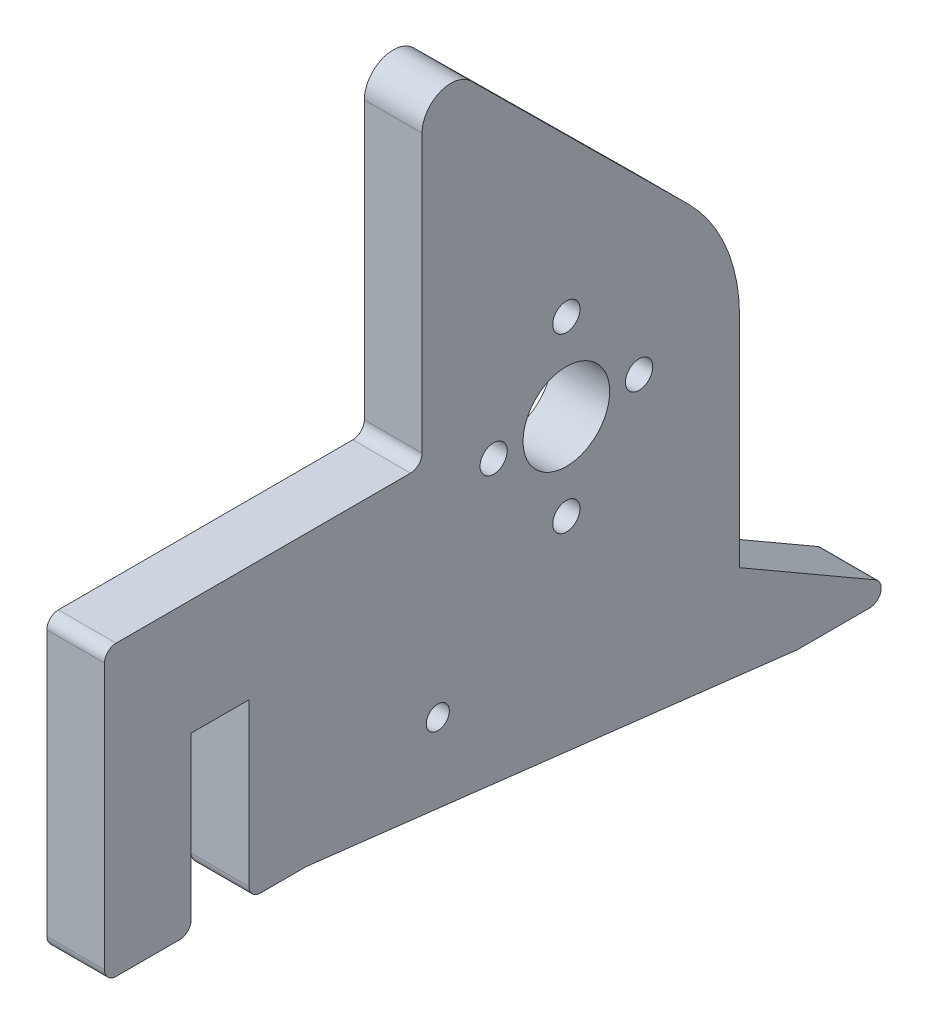
from build123d import *

# Parameters (mm, degrees)
BOSS_EXTRUDE1_DEPTH     = 3.175
CUT_EXTRUDE4_DEPTH      = 64.579325453
CUT_EXTRUDE4_DEPTH_BACK = 64.579325453
SKETCH15_W              = 6.35
SKETCH15_H              = 19.05
SKETCH37_R              = 1.5
SKETCH37_R_2            = 4.7625
CUT_EXTRUDE15_DEPTH     = 64.816710194
SKETCH47_R              = 1.27
CUT_EXTRUDE18_DEPTH     = 64.816710194
FILLET14_R              = 1.27
FILLET15_R              = 1.27


with BuildPart() as part:
    # Sketch5 → Boss-Extrude1 (new, symmetric)
    with BuildSketch(Plane(origin=(0, 0, 0), x_dir=(0, 0, -1), z_dir=(1, 0, 0))):
        with BuildLine():
            Line((19.05, -23.926477372), (19.05, 0))
            ThreePointArc((19.05, 0), (17.582566657, 7.331838088), (13.406341233, 13.534124085))
            Line((13.406341233, 13.534124085), (-10.465609794, 37.180687347))
            ThreePointArc((-10.465609794, 37.180687347), (-13.921973015, 37.855427776), (-15.875, 34.925))
            Line((-15.875, 34.925), (-15.875, 3.175))
            Line((-15.875, 3.175), (-50.8, 3.175))
            Line((-50.8, 3.175), (-50.8, -28.575))
            Line((-50.8, -28.575), (-28.575, -28.575))
            Line((-28.575, -28.575), (25.4, -34.925))
            Line((25.4, -34.925), (38.1, -34.925))
            Line((38.1, -34.925), (19.05, -23.926477372))
        make_face()
    extrude(amount=BOSS_EXTRUDE1_DEPTH, both=True)

    # Sketch15 → Cut-Extrude4 (cut, two sides: drawn at the far end of the back side and taken through both)
    with BuildSketch(Plane(origin=(0, 0, 0), x_dir=(0, 0, -1), z_dir=(1, 0, 0)).offset(-CUT_EXTRUDE4_DEPTH_BACK)):
        with Locations((-38.1, -19.05)):
            Rectangle(SKETCH15_W, SKETCH15_H)
    extrude(amount=CUT_EXTRUDE4_DEPTH + CUT_EXTRUDE4_DEPTH_BACK, mode=Mode.SUBTRACT)

    # Sketch37 → Cut-Extrude15 (cut, through all)
    with BuildSketch(Plane(origin=(3.175, 0, 0), x_dir=(0, 0, -1), z_dir=(1, 0, 0))):
        with Locations((0, -9.5)):
            Circle(SKETCH37_R)
        with Locations((0, 9.5)):
            Circle(SKETCH37_R)
        with Locations((8, 0)):
            Circle(SKETCH37_R)
        with Locations((-8, 0)):
            Circle(SKETCH37_R)
        Circle(SKETCH37_R_2)
    extrude(amount=-CUT_EXTRUDE15_DEPTH, mode=Mode.SUBTRACT)

    # Sketch47 → Cut-Extrude18 (cut, through all)
    with BuildSketch(Plane.ZY.offset(3.175)):
        with Locations((14.14272, -21.59)):
            Circle(SKETCH47_R)
    extrude(amount=-CUT_EXTRUDE18_DEPTH, mode=Mode.SUBTRACT)

    # Fillet14
    fillet14_edges = [part.edges().sort_by_distance(p)[0] for p in [
        (0, -34.925, -38.1),
    ]]
    fillet(fillet14_edges, radius=FILLET14_R)

    # Fillet15
    fillet15_edges = [part.edges().sort_by_distance(p)[0] for p in [
        (0, -28.575, 34.925),
        (0, -28.575, 41.275),
        (0, -28.575, 50.8),
        (0, 3.175, 50.8),
        (0, 3.175, 15.875),
    ]]
    fillet(fillet15_edges, radius=FILLET15_R)


solid = part.part
